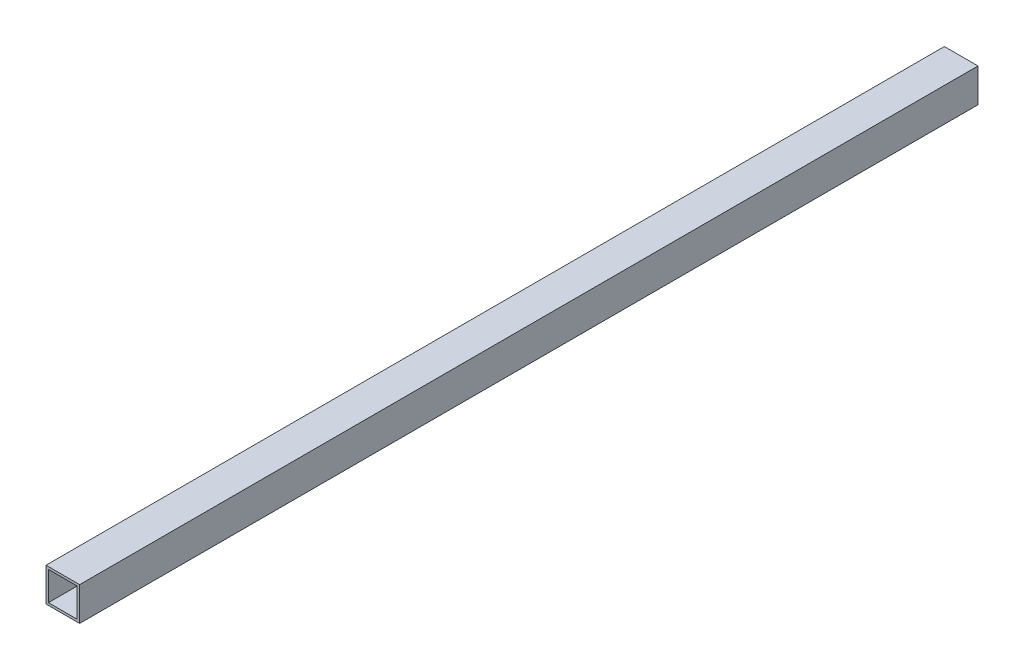
from build123d import *

# Parameters (mm, degrees)
SKETCH1_W           = 44.45
SKETCH1_H           = 44.45
SKETCH1_W_2         = 38.1
SKETCH1_H_2         = 38.1
BOSS_EXTRUDE1_DEPTH = 1187.45


with BuildPart() as part:
    # Sketch1 → Boss-Extrude1 (new body)
    with BuildSketch(Plane.XY):
        with Locations((22.225, 22.225)):
            Rectangle(SKETCH1_W, SKETCH1_H)
        with Locations((22.225, 22.225)):
            Rectangle(SKETCH1_W_2, SKETCH1_H_2, mode=Mode.SUBTRACT)
    extrude(amount=BOSS_EXTRUDE1_DEPTH)


solid = part.part
